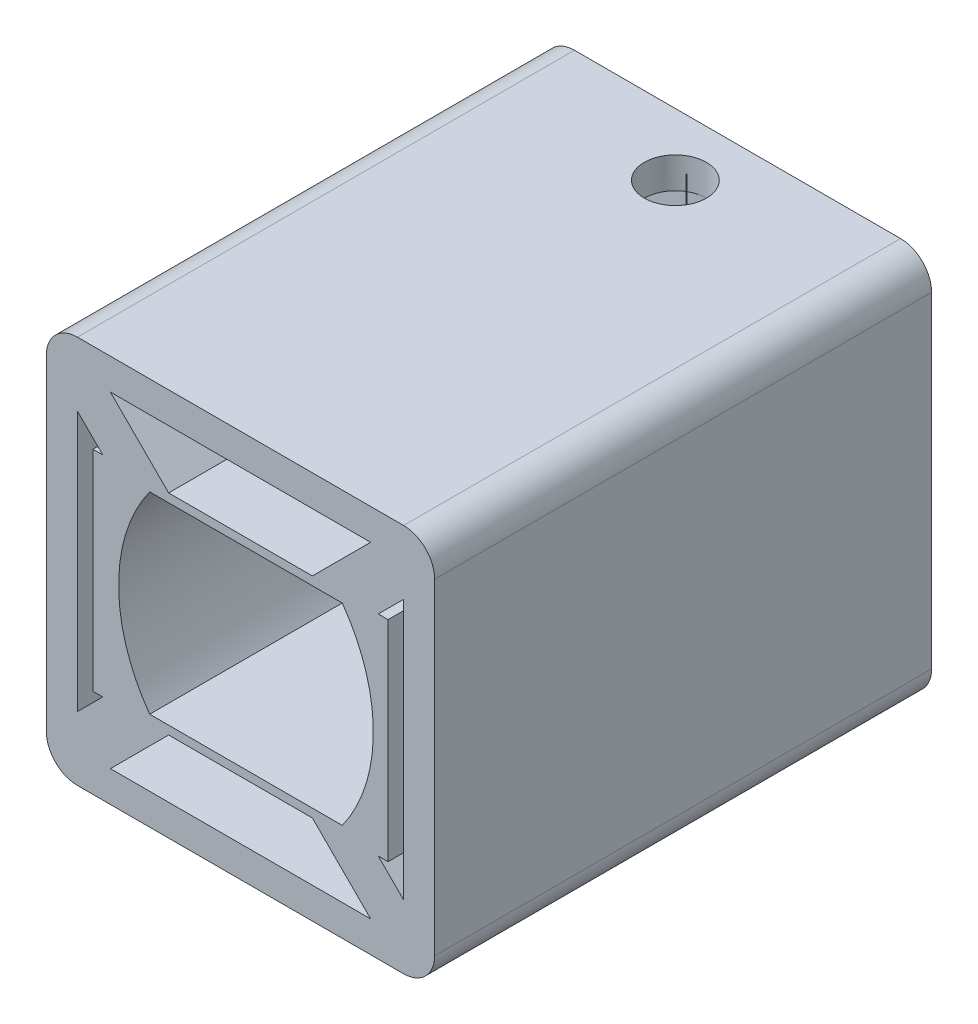
from build123d import *

# Parameters (mm, degrees)
SKETCH1_W           = 25
SKETCH1_H           = 25
BOSS_EXTRUDE1_DEPTH = 32
SHELL1_T            = -2
SKETCH2_R           = 2.5
SKETCH2_R_2         = 1.425
CUT_EXTRUDE4_DEPTH  = 2
BOSS_EXTRUDE3_DEPTH = 30
SKETCH5_R           = 2
SKETCH5_R_2         = 0.024622166
CUT_EXTRUDE6_DEPTH  = 7.5
FILLET1_R           = 2


with BuildPart() as part:
    # Sketch1 → Boss-Extrude1 (new body)
    with BuildSketch(Plane.XY):
        Rectangle(SKETCH1_W, SKETCH1_H)
    extrude(amount=BOSS_EXTRUDE1_DEPTH)

    # Shell1
    shell1_openings = [part.faces().sort_by_distance(p)[0] for p in [
        (0, 0, 32),
    ]]
    offset(amount=SHELL1_T, openings=shell1_openings, kind=Kind.INTERSECTION)

    # Sketch2 → Cut-Extrude4 (cut)
    with BuildSketch(Plane.XY):
        Circle(SKETCH2_R)
        with Locations((8.25, 0)):
            Circle(SKETCH2_R_2)
        with Locations((0, -8.25)):
            Circle(SKETCH2_R_2)
        with Locations((-8.25, 0)):
            Circle(SKETCH2_R_2)
        with Locations((0, 8.25)):
            Circle(SKETCH2_R_2)
    extrude(amount=CUT_EXTRUDE4_DEPTH, mode=Mode.SUBTRACT)

    # Sketch4 → Boss-Extrude3 (add)
    with BuildSketch(Plane.XY.offset(2)):
        with BuildLine():
            Line((-8.871320344, 6.75), (-6.773867463, 4.652547119))
            ThreePointArc((-6.773867463, 4.652547119), (-6.344045672, 5.445969686), (-5.848359857, 6.2))
            Line((-5.848359857, 6.2), (-4.078679656, 6.2))
            Line((-4.078679656, 6.2), (-4.628679656, 6.75))
            Line((-4.628679656, 6.75), (-8.871320344, 6.75))
        make_face()
        Polygon((-10.5, 8.378679656), (-8.871320344, 6.75), (-4.628679656, 6.75), (-8.378679656, 10.5), (-10.5, 10.5), align=None)
        Polygon((-4.628679656, 6.75), (-4.078679656, 6.2), (0.351640143, 6.2), (4.078679656, 6.2), (4.628679656, 6.75), align=None)
        Polygon((4.628679656, 6.75), (8.871320344, 6.75), (10.5, 8.378679656), (10.5, 10.5), (8.378679656, 10.5), align=None)
        with BuildLine():
            ThreePointArc((6.551640143, 6.2), (6.91069206, 5.668174991), (7.236937783, 5.11561744))
            Line((7.236937783, 5.11561744), (8.871320344, 6.75))
            Line((8.871320344, 6.75), (4.628679656, 6.75))
            Line((4.628679656, 6.75), (4.078679656, 6.2))
            Line((4.078679656, 6.2), (6.551640143, 6.2))
        make_face()
        with BuildLine():
            ThreePointArc((-5.848359857, -6.2), (-6.344045672, -5.445969686), (-6.773867463, -4.652547119))
            Line((-6.773867463, -4.652547119), (-8.871320344, -6.75))
            Line((-8.871320344, -6.75), (-4.628679656, -6.75))
            Line((-4.628679656, -6.75), (-4.078679656, -6.2))
            Line((-4.078679656, -6.2), (-5.848359857, -6.2))
        make_face()
        with BuildLine():
            Line((8.871320344, -6.75), (7.236937783, -5.11561744))
            ThreePointArc((7.236937783, -5.11561744), (6.91069206, -5.668174991), (6.551640143, -6.2))
            Line((6.551640143, -6.2), (4.078679656, -6.2))
            Line((4.078679656, -6.2), (4.628679656, -6.75))
            Line((4.628679656, -6.75), (8.871320344, -6.75))
        make_face()
        Polygon((-4.628679656, -6.75), (-8.871320344, -6.75), (-10.5, -8.378679656), (-10.5, -10.5), (-8.378679656, -10.5), align=None)
        Polygon((10.5, -8.378679656), (8.871320344, -6.75), (4.628679656, -6.75), (8.378679656, -10.5), (10.5, -10.5), align=None)
        with BuildLine():
            Line((8.871320344, 6.75), (7.236937783, 5.11561744))
            ThreePointArc((7.236937783, 5.11561744), (8.019057631, 3.319300647), (8.457559307, 1.409802871))
            ThreePointArc((8.457559307, 1.409802871), (9.064092068, 1.169563639), (9.5, 0.684196609))
            Line((9.5, 0.684196609), (9.5, 6.75))
            Line((9.5, 6.75), (8.871320344, 6.75))
        make_face()
        with BuildLine():
            ThreePointArc((8.457559307, -1.409802871), (8.019057631, -3.319300647), (7.236937783, -5.11561744))
            Line((7.236937783, -5.11561744), (8.871320344, -6.75))
            Line((8.871320344, -6.75), (9.5, -6.75))
            Line((9.5, -6.75), (9.5, -0.684196609))
            ThreePointArc((9.5, -0.684196609), (9.064092068, -1.169563639), (8.457559307, -1.409802871))
        make_face()
        Polygon((0.351640143, -6.2), (-4.078679656, -6.2), (-4.628679656, -6.75), (4.628679656, -6.75), (4.078679656, -6.2), align=None)
        with BuildLine():
            ThreePointArc((-6.773867463, -4.652547119), (-7.404553087, -3.03654659), (-7.76348103, -1.33937459))
            ThreePointArc((-7.76348103, -1.33937459), (-8.753031179, -1.333260902), (-9.5, -0.684196609))
            Line((-9.5, -0.684196609), (-9.5, -6.75))
            Line((-9.5, -6.75), (-8.871320344, -6.75))
            Line((-8.871320344, -6.75), (-6.773867463, -4.652547119))
        make_face()
        with BuildLine():
            ThreePointArc((-9.5, 0.684196609), (-8.753031179, 1.333260902), (-7.76348103, 1.33937459))
            ThreePointArc((-7.76348103, 1.33937459), (-7.404553087, 3.03654659), (-6.773867463, 4.652547119))
            Line((-6.773867463, 4.652547119), (-8.871320344, 6.75))
            Line((-8.871320344, 6.75), (-9.5, 6.75))
            Line((-9.5, 6.75), (-9.5, 0.684196609))
        make_face()
        with BuildLine():
            ThreePointArc((-7.76348103, -1.33937459), (-7.827118888, -0.671030682), (-7.848359857, 0))
            ThreePointArc((-7.848359857, 0), (-7.827118888, 0.671030682), (-7.76348103, 1.33937459))
            ThreePointArc((-7.76348103, 1.33937459), (-8.753031179, 1.333260902), (-9.5, 0.684196609))
            Line((-9.5, 0.684196609), (-9.5, -0.684196609))
            ThreePointArc((-9.5, -0.684196609), (-8.753031179, -1.333260902), (-7.76348103, -1.33937459))
        make_face()
        with BuildLine():
            ThreePointArc((8.457559307, 1.409802871), (8.528093807, 0.706469273), (8.551640143, 0))
            ThreePointArc((8.551640143, 0), (8.528093807, -0.706469273), (8.457559307, -1.409802871))
            ThreePointArc((8.457559307, -1.409802871), (9.064092068, -1.169563639), (9.5, -0.684196609))
            Line((9.5, -0.684196609), (9.5, 0.684196609))
            ThreePointArc((9.5, 0.684196609), (9.064092068, 1.169563639), (8.457559307, 1.409802871))
        make_face()
    extrude(amount=BOSS_EXTRUDE3_DEPTH)

    # Sketch5 → Cut-Extrude6 (cut)
    with BuildSketch(Plane(origin=(0, 12.5, 0), x_dir=(1, 0, 0), z_dir=(0, 1, 0))):
        with Locations((0, -4)):
            Circle(SKETCH5_R)
        with Locations((0.024622166, -3.301323142)):
            Circle(SKETCH5_R_2, mode=Mode.SUBTRACT)
    extrude(amount=-CUT_EXTRUDE6_DEPTH, mode=Mode.SUBTRACT)

    # Fillet1
    fillet1_edges = [part.edges().sort_by_distance(p)[0] for p in [
        (12.5, -12.5, 16),
        (12.5, 12.5, 16),
        (-12.5, 12.5, 16),
        (-12.5, -12.5, 16),
    ]]
    fillet(fillet1_edges, radius=FILLET1_R)


solid = part.part
